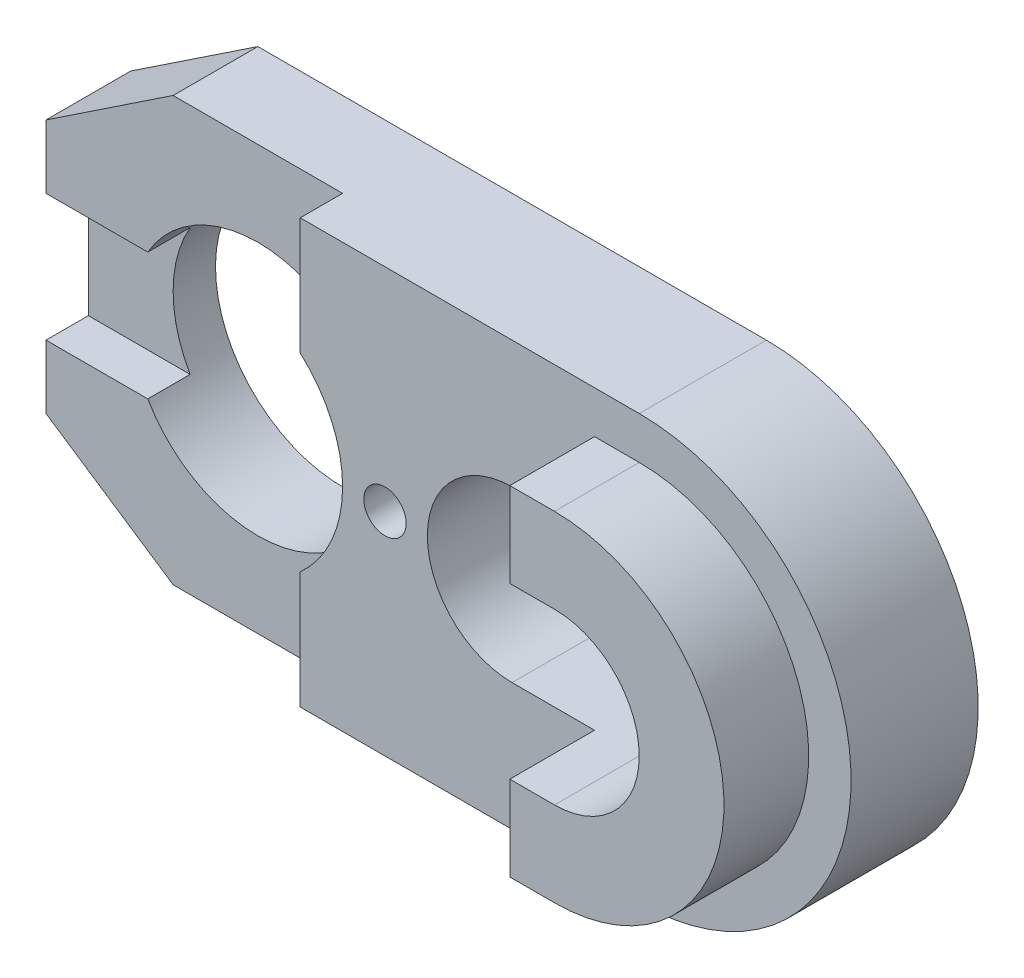
from build123d import *

# Parameters (mm, degrees)
SKETCH1_R           = 3
SKETCH1_R_2         = 0.5
BOSS_EXTRUDE1_DEPTH = 5
CUT_EXTRUDE1_DEPTH  = 25
CUT_EXTRUDE2_DEPTH  = 2
SKETCH4_W           = 1
SKETCH4_H           = 3
CUT_EXTRUDE3_DEPTH  = 3


with BuildPart() as part:
    # Sketch1 → Boss-Extrude1 (new body)
    with BuildSketch(Plane.XY):
        with BuildLine():
            Line((-9.495764101, 3), (-6.495764101, 5))
            Line((-6.495764101, 5), (5.504235899, 5))
            ThreePointArc((5.504235899, 5), (9.046847958, 3.528441554), (10.504195739, -0.02004008))
            ThreePointArc((10.504195739, -0.02004008), (9.032677453, -3.542612059), (5.504235899, -5))
            Line((5.504235899, -5), (-6.495764101, -5))
            Line((-6.495764101, -5), (-9.495764101, -3))
            Line((-9.495764101, -3), (-9.495764101, 3))
        make_face()
        with Locations((-4.495764101, 0)):
            Circle(SKETCH1_R, mode=Mode.SUBTRACT)
        with Locations((-0.495764101, 0)):
            Circle(SKETCH1_R_2, mode=Mode.SUBTRACT)
        with BuildLine():
            Line((2.504235899, 2), (5.504235899, 2))
            ThreePointArc((5.504235899, 2), (7.504235899, 0), (5.504235899, -2))
            Line((5.504235899, -2), (2.504235899, -2))
            ThreePointArc((2.504235899, -2), (0.504235899, 0), (2.504235899, 2))
        make_face(mode=Mode.SUBTRACT)
    extrude(amount=BOSS_EXTRUDE1_DEPTH)

    # Sketch2 → Cut-Extrude1 (cut)
    with BuildSketch(Plane(origin=(0, 5, 0), x_dir=(1, 0, 0), z_dir=(0, 1, 0))):
        Polygon((-9.495764101, -2), (-2.495764101, -2), (-2.495764101, -3), (4.450061274, -3), (4.450061274, -5), (9.504235899, -5), (9.504235899, -3), (10.504235899, -3), (10.504235899, -6.643116644), (-9.495764101, -6.643116644), align=None)
    extrude(amount=-CUT_EXTRUDE1_DEPTH, mode=Mode.SUBTRACT)

    # Sketch3 → Cut-Extrude2 (cut)
    with BuildSketch(Plane.XY.offset(5)):
        with BuildLine():
            Line((4.450061274, 5), (4.450061274, 4))
            Line((4.450061274, 4), (5.504235899, 4))
            ThreePointArc((5.504235899, 4), (8.332663024, 2.828427125), (9.504235899, 0))
            Line((9.504235899, 0), (9.504235899, 3))
            ThreePointArc((9.504235899, 3), (7.740303877, 4.472135955), (5.504235899, 5))
            Line((5.504235899, 5), (4.450061274, 5))
        make_face()
        with BuildLine():
            Line((5.504235899, -4), (4.450061274, -4))
            Line((4.450061274, -4), (4.450061274, -5))
            Line((4.450061274, -5), (5.504235899, -5))
            ThreePointArc((5.504235899, -5), (7.740303877, -4.472135955), (9.504235899, -3))
            Line((9.504235899, -3), (9.504235899, 0))
            ThreePointArc((9.504235899, 0), (8.332663024, -2.828427125), (5.504235899, -4))
        make_face()
        with BuildLine():
            Line((4.450061274, -4), (4.450061274, -2))
            Line((4.450061274, -2), (2.504235899, -2))
            ThreePointArc((2.504235899, -2), (0.504235899, 0), (2.504235899, 2))
            Line((2.504235899, 2), (4.450061274, 2))
            Line((4.450061274, 2), (4.450061274, 4))
            Line((4.450061274, 4), (4.429293772, 4))
            Line((4.429293772, 4), (2.504235899, 4))
            ThreePointArc((2.504235899, 4), (-1.495764101, 0), (2.504235899, -4))
            Line((2.504235899, -4), (4.450061274, -4))
        make_face()
    extrude(amount=-CUT_EXTRUDE2_DEPTH, mode=Mode.SUBTRACT)

    # Sketch4 → Cut-Extrude3 (cut)
    with BuildSketch(Plane.ZY.offset(9.495764101)):
        with Locations((1.5, 0)):
            Rectangle(SKETCH4_W, SKETCH4_H)
    extrude(amount=-CUT_EXTRUDE3_DEPTH, mode=Mode.SUBTRACT)


solid = part.part
